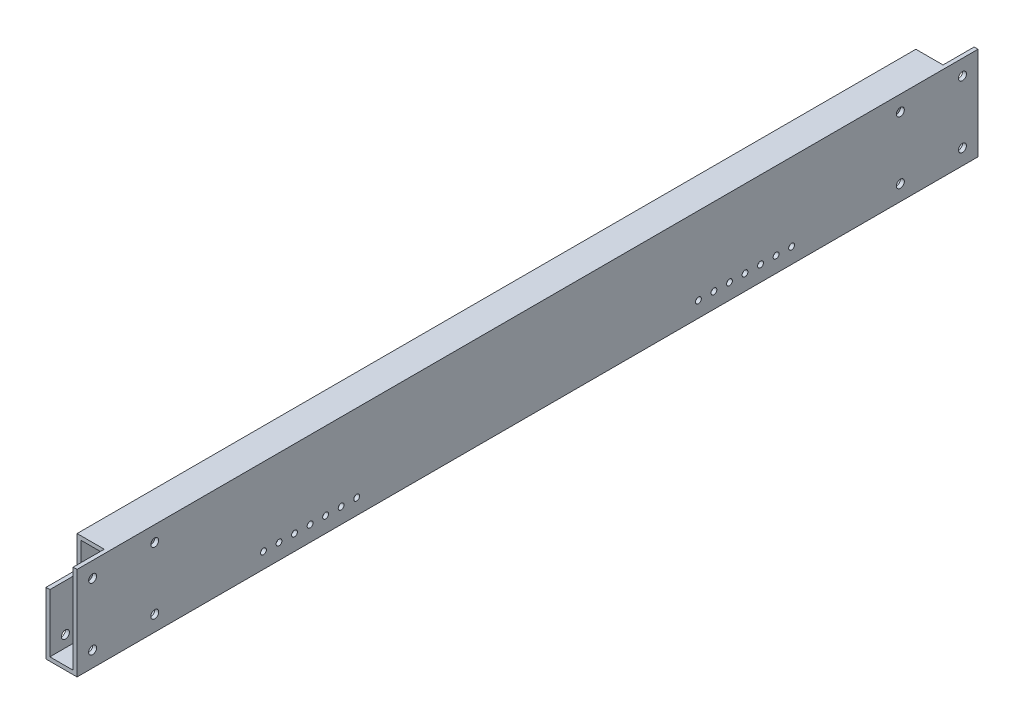
from build123d import *

# Parameters (mm, degrees)
SKETCH1_W               = 25.4
SKETCH1_H               = 76.2
BOSS_EXTRUDE1_DEPTH     = 368.3
SHELL1_T                = -3.175
CUT_EXTRUDE2_REACH      = 27.4
SKETCH3_R               = 2.38125
SKETCH4_W               = 25.4
SKETCH4_H               = 25.4
CUT_EXTRUDE3_DEPTH      = 22.225
SKETCH5_R               = 3.25
CUT_EXTRUDE4_DEPTH      = 23.225
CUT_EXTRUDE4_DEPTH_BACK = 4.175


with BuildPart() as part:
    # Sketch1 → Boss-Extrude1 (new body, symmetric)
    with BuildSketch(Plane.XY):
        Rectangle(SKETCH1_W, SKETCH1_H)
    extrude(amount=BOSS_EXTRUDE1_DEPTH, both=True)

    # Shell1
    shell1_openings = [part.faces().sort_by_distance(p)[0] for p in [
        (0, 0, 368.3),
        (0, 0, -368.3),
    ]]
    offset(amount=SHELL1_T, openings=shell1_openings, kind=Kind.INTERSECTION)

    # Sketch3 → Cut-Extrude2 (cut, up to next)
    with BuildSketch(Plane(origin=(12.7, 0, 0), x_dir=(0, 0, -1), z_dir=(1, 0, 0)), mode=Mode.PRIVATE) as cut_extrude2_sk1:
        with Locations((215.9, -25.4)):
            Circle(SKETCH3_R)
    cut_extrude2_tool1 = extrude(cut_extrude2_sk1.sketch, amount=-CUT_EXTRUDE2_REACH, mode=Mode.PRIVATE) & part.part
    add(cut_extrude2_tool1.solids().sort_by_distance((12.7, -25.4, -215.9))[0], mode=Mode.SUBTRACT)
    # Sketch3 → Cut-Extrude2 (cut, up to next)
    with BuildSketch(Plane(origin=(12.7, 0, 0), x_dir=(0, 0, -1), z_dir=(1, 0, 0)), mode=Mode.PRIVATE) as cut_extrude2_sk2:
        with Locations((203.2, -25.4)):
            Circle(SKETCH3_R)
    cut_extrude2_tool2 = extrude(cut_extrude2_sk2.sketch, amount=-CUT_EXTRUDE2_REACH, mode=Mode.PRIVATE) & part.part
    add(cut_extrude2_tool2.solids().sort_by_distance((12.7, -25.4, -203.2))[0], mode=Mode.SUBTRACT)
    # Sketch3 → Cut-Extrude2 (cut, up to next)
    with BuildSketch(Plane(origin=(12.7, 0, 0), x_dir=(0, 0, -1), z_dir=(1, 0, 0)), mode=Mode.PRIVATE) as cut_extrude2_sk3:
        with Locations((190.5, -25.4)):
            Circle(SKETCH3_R)
    cut_extrude2_tool3 = extrude(cut_extrude2_sk3.sketch, amount=-CUT_EXTRUDE2_REACH, mode=Mode.PRIVATE) & part.part
    add(cut_extrude2_tool3.solids().sort_by_distance((12.7, -25.4, -190.5))[0], mode=Mode.SUBTRACT)
    # Sketch3 → Cut-Extrude2 (cut, up to next)
    with BuildSketch(Plane(origin=(12.7, 0, 0), x_dir=(0, 0, -1), z_dir=(1, 0, 0)), mode=Mode.PRIVATE) as cut_extrude2_sk4:
        with Locations((177.8, -25.4)):
            Circle(SKETCH3_R)
    cut_extrude2_tool4 = extrude(cut_extrude2_sk4.sketch, amount=-CUT_EXTRUDE2_REACH, mode=Mode.PRIVATE) & part.part
    add(cut_extrude2_tool4.solids().sort_by_distance((12.7, -25.4, -177.8))[0], mode=Mode.SUBTRACT)
    # Sketch3 → Cut-Extrude2 (cut, up to next)
    with BuildSketch(Plane(origin=(12.7, 0, 0), x_dir=(0, 0, -1), z_dir=(1, 0, 0)), mode=Mode.PRIVATE) as cut_extrude2_sk5:
        with Locations((165.1, -25.4)):
            Circle(SKETCH3_R)
    cut_extrude2_tool5 = extrude(cut_extrude2_sk5.sketch, amount=-CUT_EXTRUDE2_REACH, mode=Mode.PRIVATE) & part.part
    add(cut_extrude2_tool5.solids().sort_by_distance((12.7, -25.4, -165.1))[0], mode=Mode.SUBTRACT)
    # Sketch3 → Cut-Extrude2 (cut, up to next)
    with BuildSketch(Plane(origin=(12.7, 0, 0), x_dir=(0, 0, -1), z_dir=(1, 0, 0)), mode=Mode.PRIVATE) as cut_extrude2_sk6:
        with Locations((152.4, -25.4)):
            Circle(SKETCH3_R)
    cut_extrude2_tool6 = extrude(cut_extrude2_sk6.sketch, amount=-CUT_EXTRUDE2_REACH, mode=Mode.PRIVATE) & part.part
    add(cut_extrude2_tool6.solids().sort_by_distance((12.7, -25.4, -152.4))[0], mode=Mode.SUBTRACT)
    # Sketch3 → Cut-Extrude2 (cut, up to next)
    with BuildSketch(Plane(origin=(12.7, 0, 0), x_dir=(0, 0, -1), z_dir=(1, 0, 0)), mode=Mode.PRIVATE) as cut_extrude2_sk7:
        with Locations((139.7, -25.4)):
            Circle(SKETCH3_R)
    cut_extrude2_tool7 = extrude(cut_extrude2_sk7.sketch, amount=-CUT_EXTRUDE2_REACH, mode=Mode.PRIVATE) & part.part
    add(cut_extrude2_tool7.solids().sort_by_distance((12.7, -25.4, -139.7))[0], mode=Mode.SUBTRACT)
    # Sketch3 → Cut-Extrude2 (cut, up to next)
    with BuildSketch(Plane(origin=(12.7, 0, 0), x_dir=(0, 0, -1), z_dir=(1, 0, 0)), mode=Mode.PRIVATE) as cut_extrude2_sk8:
        with Locations((-139.7, -25.4)):
            Circle(SKETCH3_R)
    cut_extrude2_tool8 = extrude(cut_extrude2_sk8.sketch, amount=-CUT_EXTRUDE2_REACH, mode=Mode.PRIVATE) & part.part
    add(cut_extrude2_tool8.solids().sort_by_distance((12.7, -25.4, 139.7))[0], mode=Mode.SUBTRACT)
    # Sketch3 → Cut-Extrude2 (cut, up to next)
    with BuildSketch(Plane(origin=(12.7, 0, 0), x_dir=(0, 0, -1), z_dir=(1, 0, 0)), mode=Mode.PRIVATE) as cut_extrude2_sk9:
        with Locations((-152.4, -25.4)):
            Circle(SKETCH3_R)
    cut_extrude2_tool9 = extrude(cut_extrude2_sk9.sketch, amount=-CUT_EXTRUDE2_REACH, mode=Mode.PRIVATE) & part.part
    add(cut_extrude2_tool9.solids().sort_by_distance((12.7, -25.4, 152.4))[0], mode=Mode.SUBTRACT)
    # Sketch3 → Cut-Extrude2 (cut, up to next)
    with BuildSketch(Plane(origin=(12.7, 0, 0), x_dir=(0, 0, -1), z_dir=(1, 0, 0)), mode=Mode.PRIVATE) as cut_extrude2_sk10:
        with Locations((-165.1, -25.4)):
            Circle(SKETCH3_R)
    cut_extrude2_tool10 = extrude(cut_extrude2_sk10.sketch, amount=-CUT_EXTRUDE2_REACH, mode=Mode.PRIVATE) & part.part
    add(cut_extrude2_tool10.solids().sort_by_distance((12.7, -25.4, 165.1))[0], mode=Mode.SUBTRACT)
    # Sketch3 → Cut-Extrude2 (cut, up to next)
    with BuildSketch(Plane(origin=(12.7, 0, 0), x_dir=(0, 0, -1), z_dir=(1, 0, 0)), mode=Mode.PRIVATE) as cut_extrude2_sk11:
        with Locations((-203.2, -25.4)):
            Circle(SKETCH3_R)
    cut_extrude2_tool11 = extrude(cut_extrude2_sk11.sketch, amount=-CUT_EXTRUDE2_REACH, mode=Mode.PRIVATE) & part.part
    add(cut_extrude2_tool11.solids().sort_by_distance((12.7, -25.4, 203.2))[0], mode=Mode.SUBTRACT)
    # Sketch3 → Cut-Extrude2 (cut, up to next)
    with BuildSketch(Plane(origin=(12.7, 0, 0), x_dir=(0, 0, -1), z_dir=(1, 0, 0)), mode=Mode.PRIVATE) as cut_extrude2_sk12:
        with Locations((-177.8, -25.4)):
            Circle(SKETCH3_R)
    cut_extrude2_tool12 = extrude(cut_extrude2_sk12.sketch, amount=-CUT_EXTRUDE2_REACH, mode=Mode.PRIVATE) & part.part
    add(cut_extrude2_tool12.solids().sort_by_distance((12.7, -25.4, 177.8))[0], mode=Mode.SUBTRACT)
    # Sketch3 → Cut-Extrude2 (cut, up to next)
    with BuildSketch(Plane(origin=(12.7, 0, 0), x_dir=(0, 0, -1), z_dir=(1, 0, 0)), mode=Mode.PRIVATE) as cut_extrude2_sk13:
        with Locations((-215.9, -25.4)):
            Circle(SKETCH3_R)
    cut_extrude2_tool13 = extrude(cut_extrude2_sk13.sketch, amount=-CUT_EXTRUDE2_REACH, mode=Mode.PRIVATE) & part.part
    add(cut_extrude2_tool13.solids().sort_by_distance((12.7, -25.4, 215.9))[0], mode=Mode.SUBTRACT)
    # Sketch3 → Cut-Extrude2 (cut, up to next)
    with BuildSketch(Plane(origin=(12.7, 0, 0), x_dir=(0, 0, -1), z_dir=(1, 0, 0)), mode=Mode.PRIVATE) as cut_extrude2_sk14:
        with Locations((-190.5, -25.4)):
            Circle(SKETCH3_R)
    cut_extrude2_tool14 = extrude(cut_extrude2_sk14.sketch, amount=-CUT_EXTRUDE2_REACH, mode=Mode.PRIVATE) & part.part
    add(cut_extrude2_tool14.solids().sort_by_distance((12.7, -25.4, 190.5))[0], mode=Mode.SUBTRACT)

    # Sketch4 → Cut-Extrude3 (cut)
    with BuildSketch(Plane.ZY.offset(12.7)):
        with Locations((-355.6, 25.4)):
            Rectangle(SKETCH4_W, SKETCH4_H)
        with Locations((355.6, 25.4)):
            Rectangle(SKETCH4_W, SKETCH4_H)
    extrude(amount=-CUT_EXTRUDE3_DEPTH, mode=Mode.SUBTRACT)

    # Sketch5 → Cut-Extrude4 (cut, two sides)
    with BuildSketch(Plane.ZY.offset(-9.525)) as cut_extrude4_sk:
        with Locations((-355.6, 25.4)):
            Circle(SKETCH5_R)
        with Locations((355.6, 25.4)):
            Circle(SKETCH5_R)
        with Locations((-355.6, -25.4)):
            Circle(SKETCH5_R)
        with Locations((-304.8, -25.4)):
            Circle(SKETCH5_R)
        with Locations((-304.8, 25.4)):
            Circle(SKETCH5_R)
        with Locations((304.8, 25.4)):
            Circle(SKETCH5_R)
        with Locations((304.8, -25.4)):
            Circle(SKETCH5_R)
        with Locations((355.6, -25.4)):
            Circle(SKETCH5_R)
    extrude(amount=CUT_EXTRUDE4_DEPTH, mode=Mode.SUBTRACT)
    extrude(cut_extrude4_sk.sketch, amount=-CUT_EXTRUDE4_DEPTH_BACK, mode=Mode.SUBTRACT)


solid = part.part
